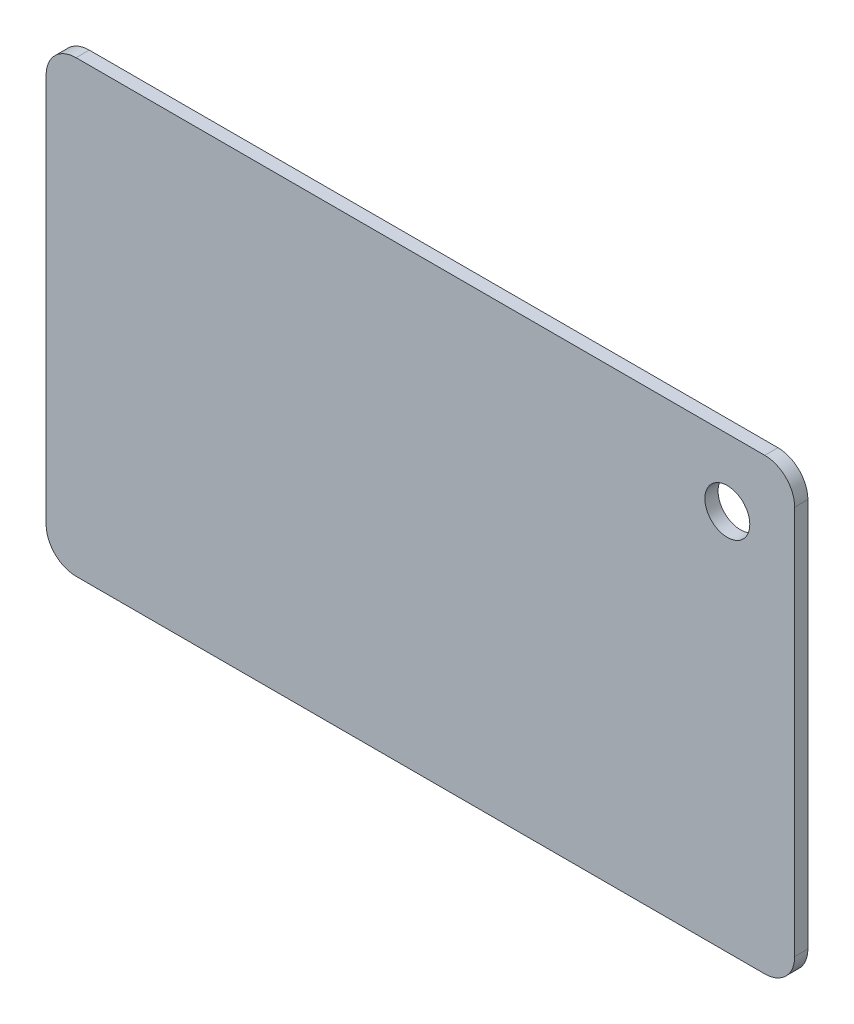
from build123d import *

# Parameters (mm, degrees)
SKETCH1_R           = 1.5
BOSS_EXTRUDE1_DEPTH = 0.88


with BuildPart() as part:
    # Sketch1 → Boss-Extrude1 (new body)
    with BuildSketch(Plane.XY):
        with BuildLine():
            Line((23, 15), (-23, 15))
            ThreePointArc((-23, 15), (-24.414213562, 14.414213562), (-25, 13))
            Line((-25, 13), (-25, -13))
            ThreePointArc((-25, -13), (-24.414213562, -14.414213562), (-23, -15))
            Line((-23, -15), (23, -15))
            ThreePointArc((23, -15), (24.414213562, -14.414213562), (25, -13))
            Line((25, -13), (25, 13))
            ThreePointArc((25, 13), (24.414213562, 14.414213562), (23, 15))
        make_face()
        with Locations((20.5, 10.5)):
            Circle(SKETCH1_R, mode=Mode.SUBTRACT)
    extrude(amount=BOSS_EXTRUDE1_DEPTH)


solid = part.part
